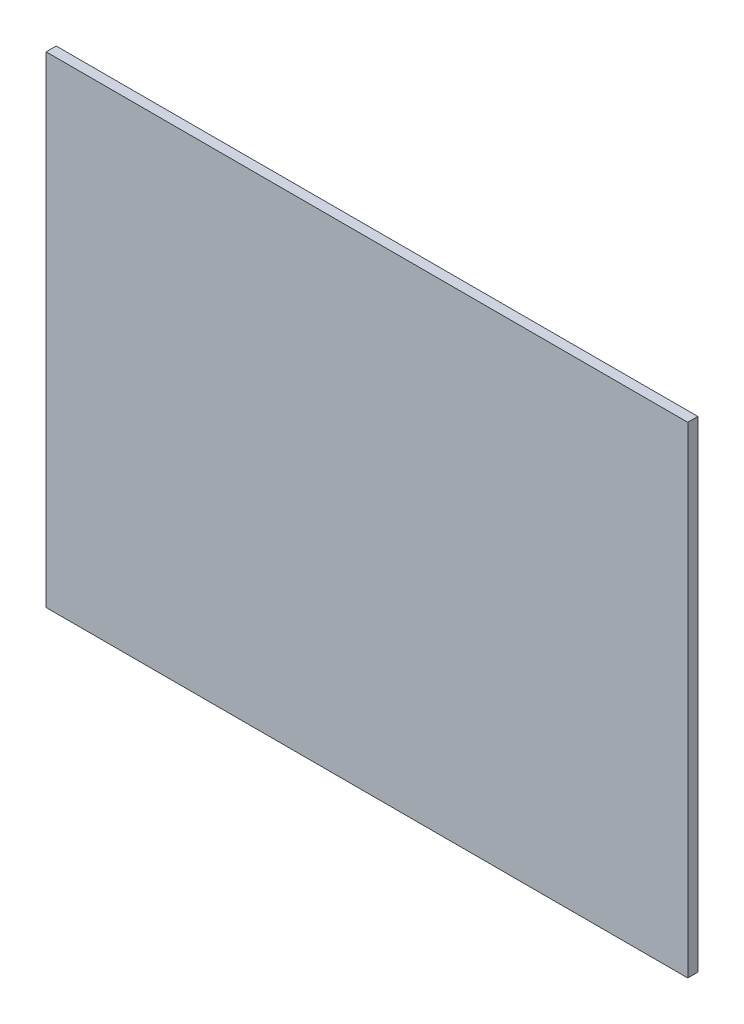
from build123d import *

# Parameters (mm, degrees)
SKETCH1_W           = 25.4
SKETCH1_H           = 19.05
BOSS_EXTRUDE1_DEPTH = 0.4


with BuildPart() as part:
    # Sketch1 → Boss-Extrude1 (new body)
    with BuildSketch(Plane.XY):
        Rectangle(SKETCH1_W, SKETCH1_H)
    extrude(amount=BOSS_EXTRUDE1_DEPTH)


solid = part.part
